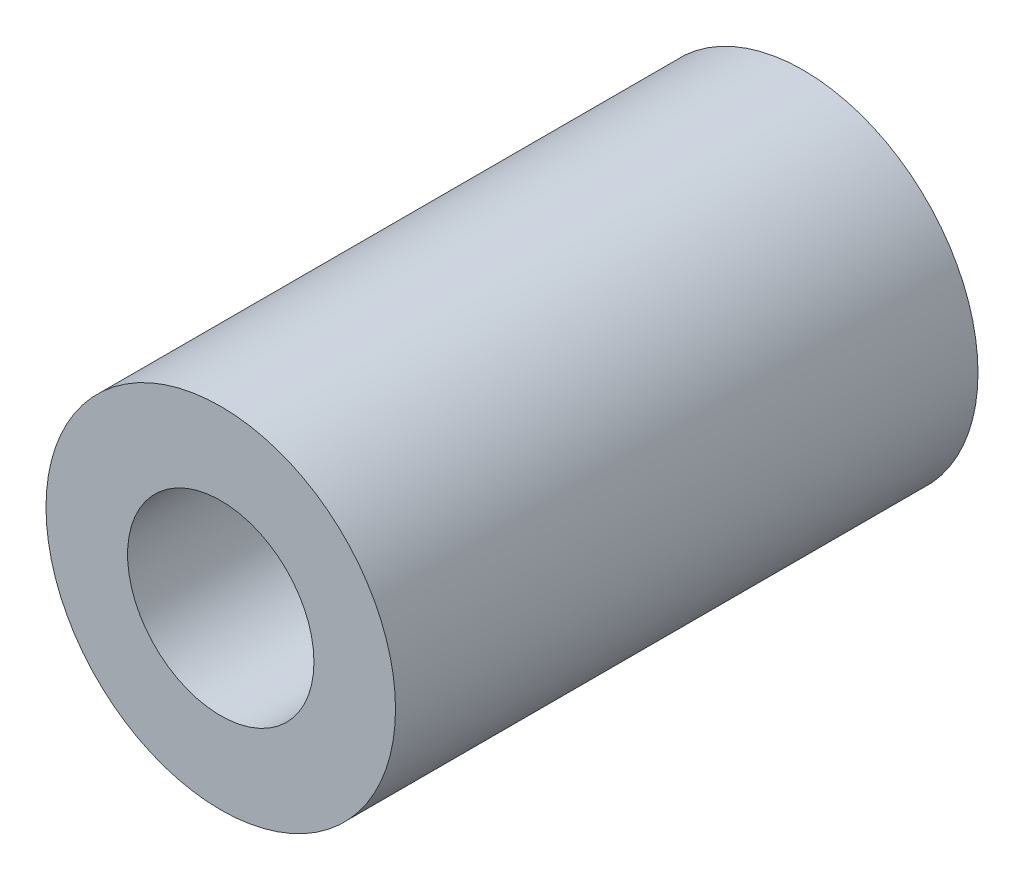
from build123d import *

# Parameters (mm, degrees)
SKETCH1_R           = 3
SKETCH1_R_2         = 1.6
BOSS_EXTRUDE1_DEPTH = 10


with BuildPart() as part:
    # Sketch1 → Boss-Extrude1 (new body)
    with BuildSketch(Plane.XY):
        Circle(SKETCH1_R)
        Circle(SKETCH1_R_2, mode=Mode.SUBTRACT)
    extrude(amount=BOSS_EXTRUDE1_DEPTH)


solid = part.part
